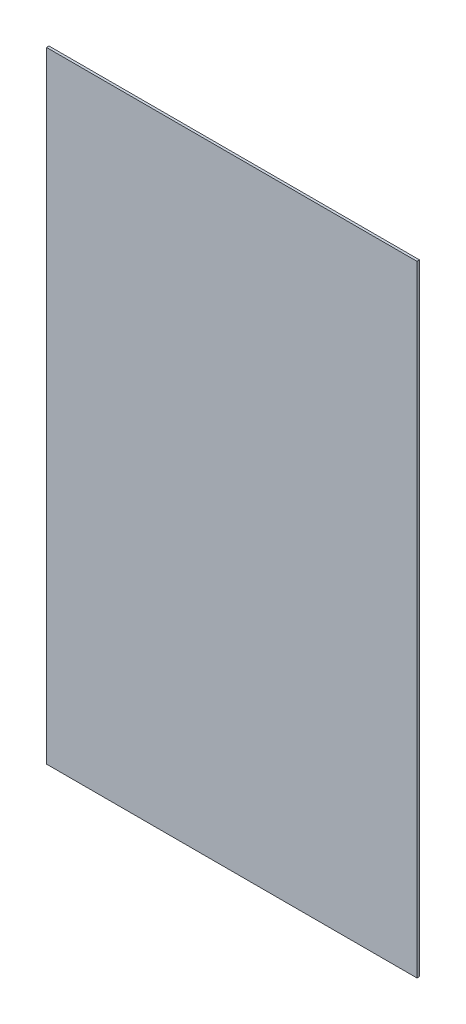
from build123d import *

# Parameters (mm, degrees)
SKETCH1_W           = 296
SKETCH1_H           = 496
BOSS_EXTRUDE1_DEPTH = 2


with BuildPart() as part:
    # Sketch1 → Boss-Extrude1 (new body)
    with BuildSketch(Plane.XY):
        with Locations((63.96326478, 30.697874425)):
            Rectangle(SKETCH1_W, SKETCH1_H)
    extrude(amount=BOSS_EXTRUDE1_DEPTH)


solid = part.part
